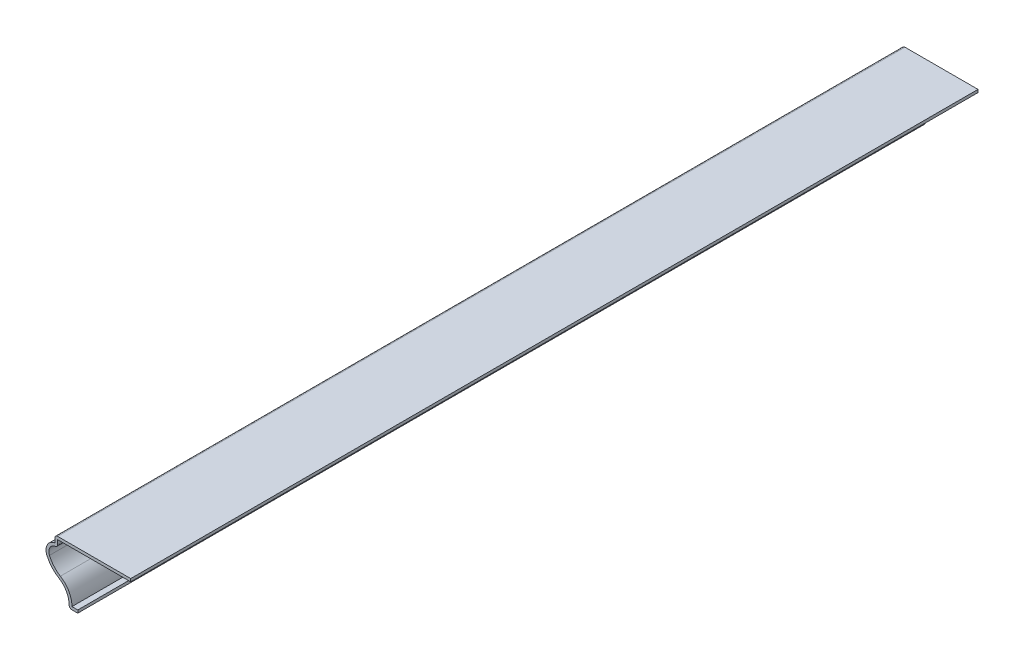
from build123d import *

# Parameters (mm, degrees)
EXTRUDE_THIN1_DEPTH = 381
FILLET1_R           = 1.27


with BuildPart() as part:
    # Sketch1 → Extrude-Thin1 (new body)
    with BuildSketch(Plane.XY):
        with BuildLine():
            Line((0, 0), (-3.96875, 0))
            ThreePointArc((-3.96875, 0), (-4.818127422, 5.384319506), (-8.48088981, 9.421213144))
            ThreePointArc((-8.48088981, 9.421213144), (-11.680182616, 12.112043916), (-13.902370802, 15.652937077))
            ThreePointArc((-13.902370802, 15.652937077), (-13.70628274, 19.809085553), (-10.31875, 22.225))
            Line((-10.31875, 22.225), (-10.31875, 25.4))
            Line((-10.31875, 25.4), (23.8125, 25.4))
            Line((23.8125, 25.4), (23.8125, 24.13))
            Line((23.8125, 24.13), (-9.04875, 24.13))
            Line((-9.04875, 24.13), (-9.04875, 20.988987709))
            ThreePointArc((-9.04875, 20.988987709), (-12.302505111, 19.646426389), (-12.735071921, 16.153250302))
            ThreePointArc((-12.735071921, 16.153250302), (-10.722030859, 12.945617675), (-7.823847964, 10.508041563))
            ThreePointArc((-7.823847964, 10.508041563), (-4.006030041, 6.572994806), (-2.613703655, 1.27))
            Line((-2.613703655, 1.27), (0, 1.27))
            Line((0, 1.27), (0, 0))
        make_face()
    extrude(amount=-EXTRUDE_THIN1_DEPTH)

    # Fillet1
    fillet1_edges = [part.edges().sort_by_distance(p)[0] for p in [
        (-9.04875, 20.988987709, -190.5),
        (-3.96875, 0, -190.5),
        (-10.31875, 25.4, -190.5),
    ]]
    fillet(fillet1_edges, radius=FILLET1_R)


solid = part.part
